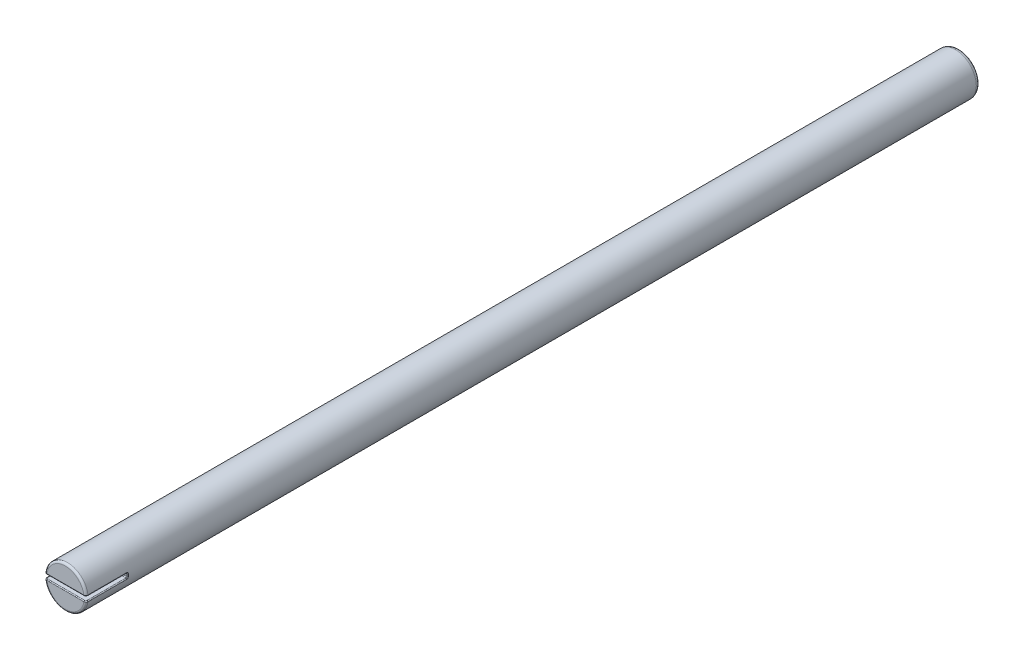
from build123d import *

# Parameters (mm, degrees)
SKETCH1_R           = 0.5
BOSS_EXTRUDE1_DEPTH = 21.5
SKETCH2_W           = 1.609185638
SKETCH2_H           = 0.1
CUT_EXTRUDE1_DEPTH  = 1
FILLET1_R           = 0.1
FILLET2_R           = 0.05
FILLET3_R           = 0.02


with BuildPart() as part:
    # Sketch1 → Boss-Extrude1 (new body)
    with BuildSketch(Plane.XY):
        Circle(SKETCH1_R)
    extrude(amount=BOSS_EXTRUDE1_DEPTH)

    # Sketch2 → Cut-Extrude1 (cut)
    with BuildSketch(Plane.XY.offset(21.5)):
        with Locations((0.143244603, 0)):
            Rectangle(SKETCH2_W, SKETCH2_H)
    extrude(amount=-CUT_EXTRUDE1_DEPTH, mode=Mode.SUBTRACT)

    # Fillet1
    fillet1_edges = [part.edges().sort_by_distance(p)[0] for p in [
        (-0.5, 0, 0),
    ]]
    fillet(fillet1_edges, radius=FILLET1_R)

    # Fillet2
    fillet2_edges = [part.edges().sort_by_distance(p)[0] for p in [
        (0, 0.5, 21.5),
        (0, -0.5, 21.5),
    ]]
    fillet(fillet2_edges, radius=FILLET2_R)

    # Fillet3
    fillet3_edges = [part.edges().sort_by_distance(p)[0] for p in [
        (0, 0.05, 20.5),
        (-0.497493719, 0.05, 20.975),
        (0, -0.05, 20.5),
        (0.497493719, -0.05, 20.975),
        (0, -0.05, 21.5),
        (-0.497493719, -0.05, 20.975),
        (-0.482618709, -0.05, 21.485508179),
        (0.482720177, -0.05, 21.485407837),
        (0.497493719, 0.05, 20.975),
        (0, 0.05, 21.5),
        (0.482618709, 0.05, 21.485508179),
        (-0.482720177, 0.05, 21.485407837),
        (0.499373037, -0.025031388, 20.5),
        (-0.5, 0, 20.5),
    ]]
    fillet(fillet3_edges, radius=FILLET3_R)


solid = part.part
